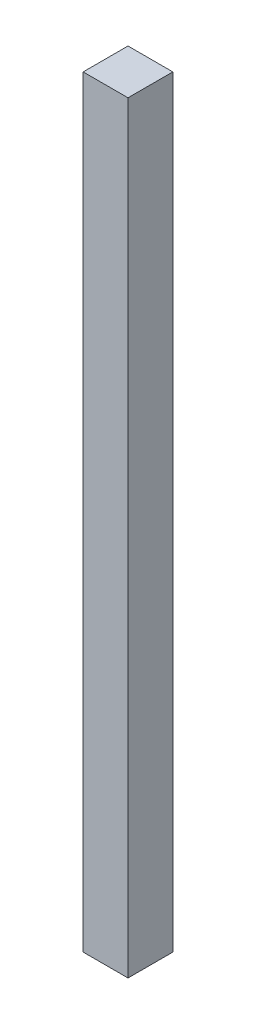
from build123d import *

# Parameters (mm, degrees)
SKETCH1_W           = 25.4
SKETCH1_H           = 431.8
BOSS_EXTRUDE1_DEPTH = 25.4


with BuildPart() as part:
    # Sketch1 → Boss-Extrude1 (new body)
    with BuildSketch(Plane.XY):
        Rectangle(SKETCH1_W, SKETCH1_H)
    extrude(amount=BOSS_EXTRUDE1_DEPTH)


solid = part.part
